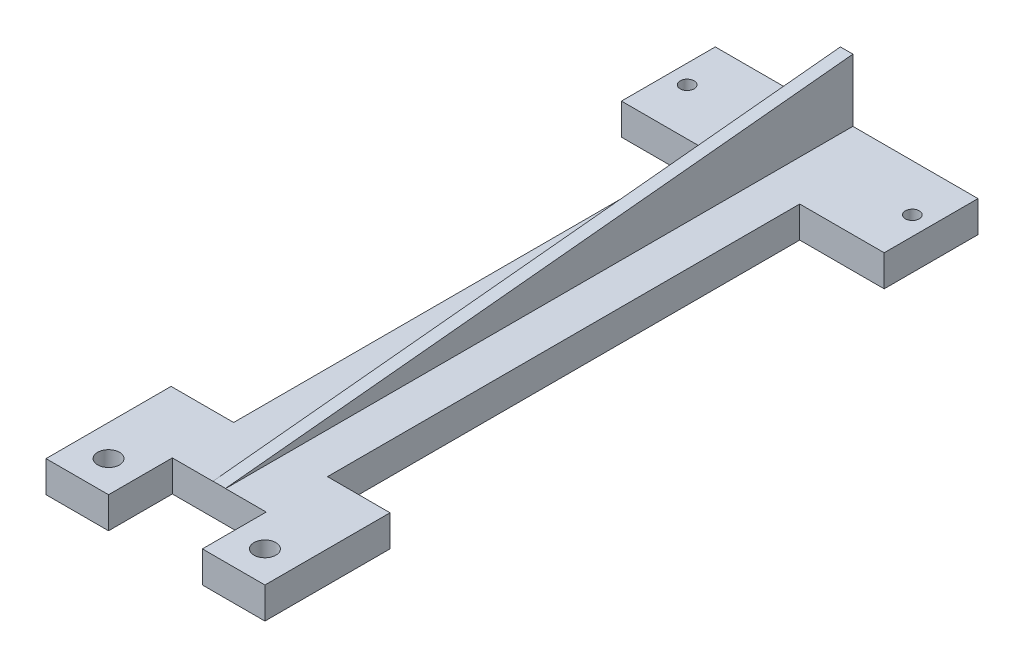
from build123d import *

# Parameters (mm, degrees)
SKETCH1_W           = 42
SKETCH1_H           = 15
BOSS_EXTRUDE1_DEPTH = 5
SKETCH2_R           = 1.115
CUT_EXTRUDE1_DEPTH  = 6
SKETCH3_W           = 15
SKETCH3_H           = 75.5
BOSS_EXTRUDE2_DEPTH = 5
SKETCH4_W           = 35
SKETCH4_H           = 10
BOSS_EXTRUDE3_DEPTH = 5
SKETCH5_W           = 10
SKETCH5_H           = 10
BOSS_EXTRUDE4_DEPTH = 5
SKETCH6_R           = 1.75
CUT_EXTRUDE2_DEPTH  = 6
SKETCH7_W           = 15
SKETCH7_H           = 0.2
CUT_EXTRUDE3_DEPTH  = 6
SKETCH8_W           = 2
SKETCH8_H           = 100.3
BOSS_EXTRUDE5_DEPTH = 10
CUT_EXTRUDE4_DEPTH  = 23


with BuildPart() as part:
    # Sketch1 → Boss-Extrude1 (new body)
    with BuildSketch(Plane(origin=(0, 0, 0), x_dir=(1, 0, 0), z_dir=(0, 1, 0))):
        with Locations((21, 7.5)):
            Rectangle(SKETCH1_W, SKETCH1_H)
    extrude(amount=BOSS_EXTRUDE1_DEPTH)

    # Sketch2 → Cut-Extrude1 (cut, through all)
    with BuildSketch(Plane(origin=(0, 5, 0), x_dir=(1, 0, 0), z_dir=(0, 1, 0))):
        with Locations((3, 7.5)):
            Circle(SKETCH2_R)
        with Locations((39, 7.5)):
            Circle(SKETCH2_R)
    extrude(amount=-CUT_EXTRUDE1_DEPTH, mode=Mode.SUBTRACT)

    # Sketch3 → Boss-Extrude2 (add)
    with BuildSketch(Plane(origin=(0, 5, 0), x_dir=(1, 0, 0), z_dir=(0, 1, 0))):
        with Locations((21, -37.75)):
            Rectangle(SKETCH3_W, SKETCH3_H)
    extrude(amount=-BOSS_EXTRUDE2_DEPTH)

    # Sketch4 → Boss-Extrude3 (add)
    with BuildSketch(Plane(origin=(0, 5, 0), x_dir=(1, 0, 0), z_dir=(0, 1, 0))):
        with Locations((21, -80.5)):
            Rectangle(SKETCH4_W, SKETCH4_H)
    extrude(amount=-BOSS_EXTRUDE3_DEPTH)

    # Sketch5 → Boss-Extrude4 (add)
    with BuildSketch(Plane(origin=(0, 5, 0), x_dir=(1, 0, 0), z_dir=(0, 1, 0))):
        with Locations((8.5, -90.5)):
            Rectangle(SKETCH5_W, SKETCH5_H)
        with Locations((33.5, -90.5)):
            Rectangle(SKETCH5_W, SKETCH5_H)
    extrude(amount=-BOSS_EXTRUDE4_DEPTH)

    # Sketch6 → Cut-Extrude2 (cut, through all)
    with BuildSketch(Plane(origin=(0, 5, 0), x_dir=(1, 0, 0), z_dir=(0, 1, 0))):
        with Locations((8.5, -90.5)):
            Circle(SKETCH6_R)
        with Locations((33.5, -90.5)):
            Circle(SKETCH6_R)
    extrude(amount=-CUT_EXTRUDE2_DEPTH, mode=Mode.SUBTRACT)

    # Sketch7 → Cut-Extrude3 (cut, through all)
    with BuildSketch(Plane(origin=(0, 5, 0), x_dir=(1, 0, 0), z_dir=(0, 1, 0))):
        with Locations((21, -85.4)):
            Rectangle(SKETCH7_W, SKETCH7_H)
    extrude(amount=-CUT_EXTRUDE3_DEPTH, mode=Mode.SUBTRACT)

    # Sketch8 → Boss-Extrude5 (add)
    with BuildSketch(Plane(origin=(0, 5, 0), x_dir=(1, 0, 0), z_dir=(0, 1, 0))):
        with Locations((21, -35.15)):
            Rectangle(SKETCH8_W, SKETCH8_H)
    extrude(amount=BOSS_EXTRUDE5_DEPTH)

    # Sketch9 → Cut-Extrude4 (cut, through all)
    with BuildSketch(Plane.ZY.offset(-20)):
        Polygon((-15, 15), (85.5, 5), (85.3, 15), align=None)
    extrude(amount=-CUT_EXTRUDE4_DEPTH, mode=Mode.SUBTRACT)


solid = part.part
